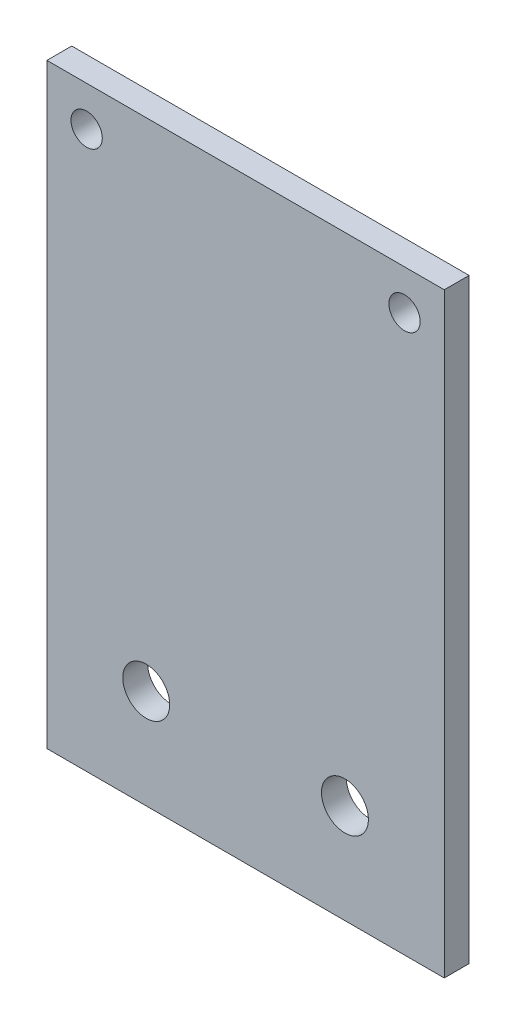
from build123d import *

# Parameters (mm, degrees)
SKETCH1_W           = 50.8
SKETCH1_H           = 76.2
BOSS_EXTRUDE1_DEPTH = 3.175
SKETCH2_R           = 2
SKETCH2_R_2         = 3
CUT_EXTRUDE1_DEPTH  = 4.175


with BuildPart() as part:
    # Sketch1 → Boss-Extrude1 (new body)
    with BuildSketch(Plane.XY):
        with Locations((25.4, 38.1)):
            Rectangle(SKETCH1_W, SKETCH1_H)
    extrude(amount=BOSS_EXTRUDE1_DEPTH)

    # Sketch2 → Cut-Extrude1 (cut, through all)
    with BuildSketch(Plane.XY.offset(3.175)):
        with Locations((5.08, 71.12)):
            Circle(SKETCH2_R)
        with Locations((45.72, 71.12)):
            Circle(SKETCH2_R)
        with Locations((12.7, 12.7)):
            Circle(SKETCH2_R_2)
        with Locations((38.1, 12.7)):
            Circle(SKETCH2_R_2)
    extrude(amount=-CUT_EXTRUDE1_DEPTH, mode=Mode.SUBTRACT)


solid = part.part
